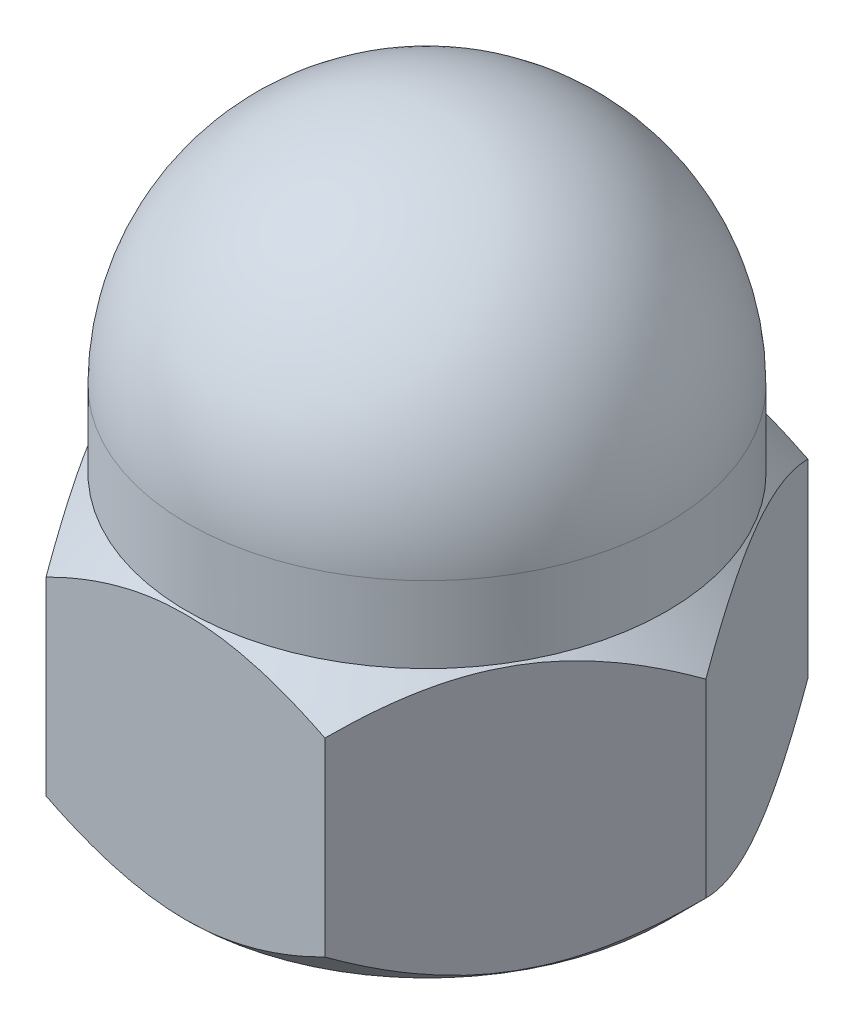
from build123d import *

# Parameters (mm, degrees)
BOSS_EXTRUDE1_DEPTH        = 19
F_20_0MM_DOWEL_HOLE1_D     = 24
F_20_0MM_DOWEL_HOLE1_DEPTH = 31.5
F_20_0MM_DOWEL_HOLE1_TIP   = 7.210327428


with BuildPart() as part:
    # Sketch1 → Boss-Extrude1 (new body)
    with BuildSketch(Plane(origin=(0, 0, 0), x_dir=(1, 0, 0), z_dir=(0, 1, 0))):
        Polygon((19.775, 0), (9.8875, 17.12565236), (-9.8875, 17.12565236), (-19.775, 0), (-9.8875, -17.12565236), (9.8875, -17.12565236), align=None)
    extrude(amount=BOSS_EXTRUDE1_DEPTH)

    # Sketch2 → Revolve1 (revolve)
    with BuildSketch(Plane.ZY):
        with BuildLine():
            Line((-17, 24.4), (-17, 19))
            Line((-17, 19), (0, 19))
            Line((0, 19), (0, 41.4))
            ThreePointArc((0, 41.4), (-12.02081528, 36.42081528), (-17, 24.4))
        make_face()
    revolve(axis=Axis((0, -1000, 0), (0, 1, 0)))

    # Ø20.0mm Dowel Hole1
    with Locations(Plane(origin=(0, 0, 0), x_dir=(-1, 0, 0), z_dir=(0, -1, 0))):
        with Locations((0, 0)):
            Hole(F_20_0MM_DOWEL_HOLE1_D / 2, depth=F_20_0MM_DOWEL_HOLE1_DEPTH)
            with Locations((0, 0, -(F_20_0MM_DOWEL_HOLE1_DEPTH + F_20_0MM_DOWEL_HOLE1_TIP / 2))):  # 118° drill point
                Cone(0, F_20_0MM_DOWEL_HOLE1_D / 2, F_20_0MM_DOWEL_HOLE1_TIP, mode=Mode.SUBTRACT)

    # Sketch6 → Cut-Revolve1 (revolve, cut)
    with BuildSketch(Plane.XY):
        Polygon((19.775, 19), (17, 19), (19.775, 16.225), align=None)
        Polygon((19.775, 2.775), (19.775, 0), (17, 0), align=None)
    revolve(axis=Axis((0, -1000, 0), (0, 1, 0)), mode=Mode.SUBTRACT)


solid = part.part
